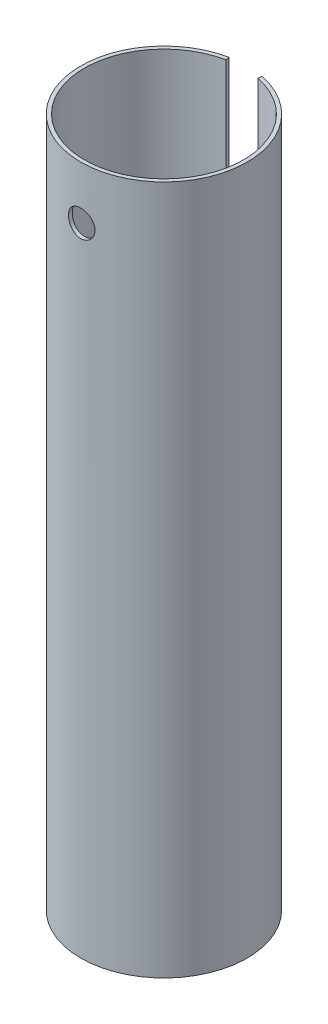
from build123d import *

# Parameters (mm, degrees)
EXTRUDE_1_DEPTH     = 13
SKETCH_2_R          = 0.25
CUT_EXTRUDE_1_DEPTH = 2.57


with BuildPart() as part:
    # Эскиз1 → Бобышка-Вытянуть1 (new body)
    with BuildSketch(Plane(origin=(0, 0, 0), x_dir=(1, 0, 0), z_dir=(0, 1, 0))):
        with BuildLine():
            Line((-0.314, 1.538279558), (-0.3, 1.469693846))
            ThreePointArc((-0.3, 1.469693846), (0, -1.5), (0.3, 1.469693846))
            Line((0.3, 1.469693846), (0.314, 1.538279558))
            ThreePointArc((0.314, 1.538279558), (0, -1.57), (-0.314, 1.538279558))
        make_face()
    extrude(amount=EXTRUDE_1_DEPTH)

    # Эскиз2 → Вырез-Вытянуть1 (cut, through all)
    with BuildSketch(Plane.XY):
        with Locations((0, 12)):
            Circle(SKETCH_2_R)
    extrude(amount=CUT_EXTRUDE_1_DEPTH, mode=Mode.SUBTRACT)


solid = part.part
